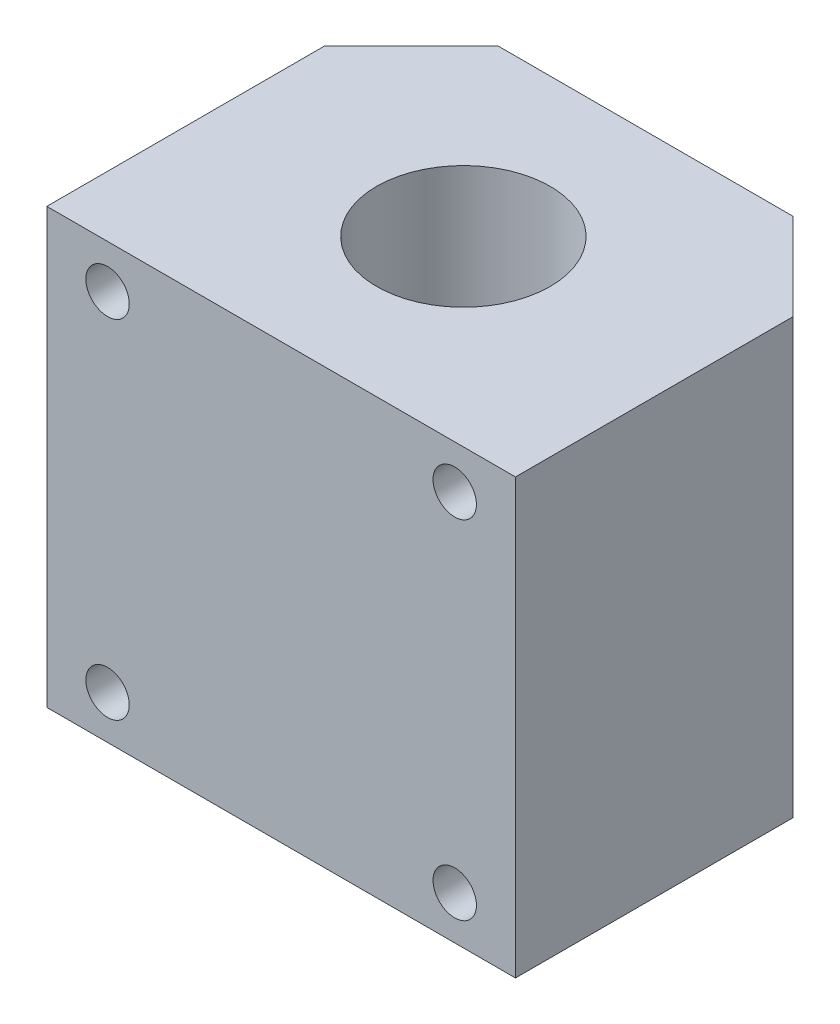
from build123d import *

# Parameters (mm, degrees)
SKETCH1_W           = 54
SKETCH1_H           = 50
BOSS_EXTRUDE1_DEPTH = 42
CHAMFER1_SIZE       = 10
SKETCH2_R           = 10
CUT_EXTRUDE1_DEPTH  = 51
SKETCH3_R           = 2.5
CUT_EXTRUDE2_DEPTH  = 15


with BuildPart() as part:
    # Sketch1 → Boss-Extrude1 (new body)
    with BuildSketch(Plane.XY):
        Rectangle(SKETCH1_W, SKETCH1_H)
    extrude(amount=BOSS_EXTRUDE1_DEPTH)

    # Chamfer1
    chamfer1_edges = [part.edges().sort_by_distance(p)[0] for p in [
        (27, 0, 0),
        (-27, 0, 0),
    ]]
    chamfer(chamfer1_edges, length=CHAMFER1_SIZE)

    # Sketch2 → Cut-Extrude1 (cut, through all)
    with BuildSketch(Plane(origin=(0, 25, 0), x_dir=(1, 0, 0), z_dir=(0, 1, 0))):
        with Locations((0, -21)):
            Circle(SKETCH2_R)
    extrude(amount=-CUT_EXTRUDE1_DEPTH, mode=Mode.SUBTRACT)

    # Sketch3 → Cut-Extrude2 (cut)
    with BuildSketch(Plane.XY.offset(42)):
        with Locations((-20, 20)):
            Circle(SKETCH3_R)
        with Locations((20, 20)):
            Circle(SKETCH3_R)
        with Locations((-20, -20)):
            Circle(SKETCH3_R)
        with Locations((20, -20)):
            Circle(SKETCH3_R)
    extrude(amount=-CUT_EXTRUDE2_DEPTH, mode=Mode.SUBTRACT)


solid = part.part
